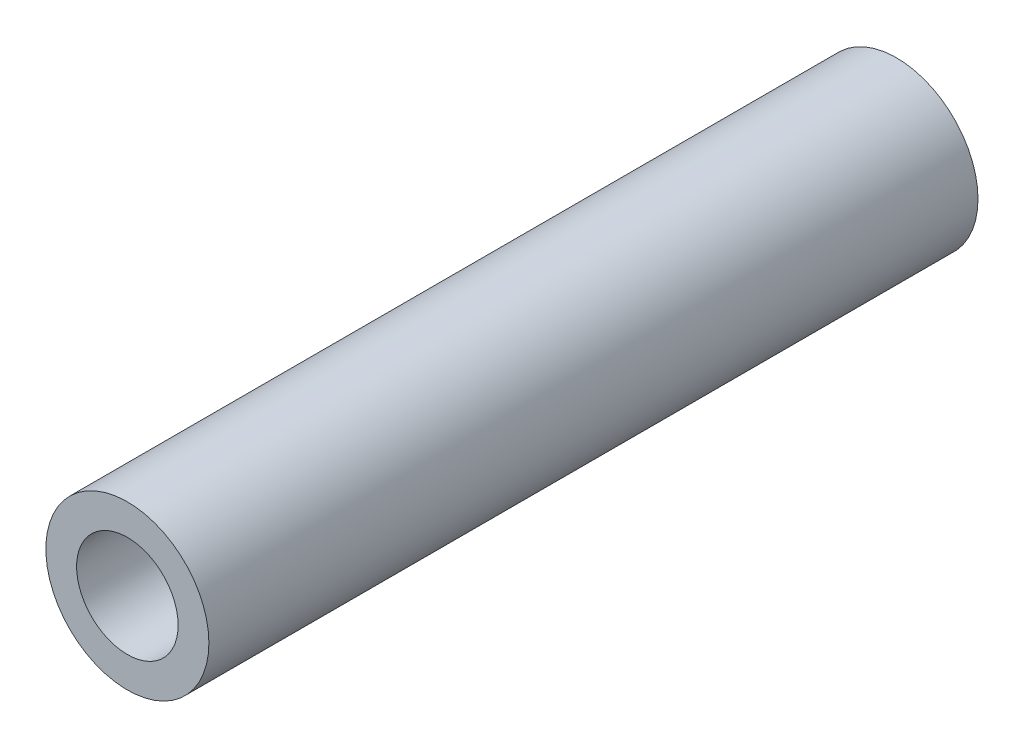
from build123d import *

# Parameters (mm, degrees)
SKETCH1_R           = 2.65
SKETCH1_R_2         = 1.65
BOSS_EXTRUDE1_DEPTH = 25


with BuildPart() as part:
    # Sketch1 → Boss-Extrude1 (new body)
    with BuildSketch(Plane.XY):
        Circle(SKETCH1_R)
        Circle(SKETCH1_R_2, mode=Mode.SUBTRACT)
    extrude(amount=BOSS_EXTRUDE1_DEPTH)


solid = part.part
